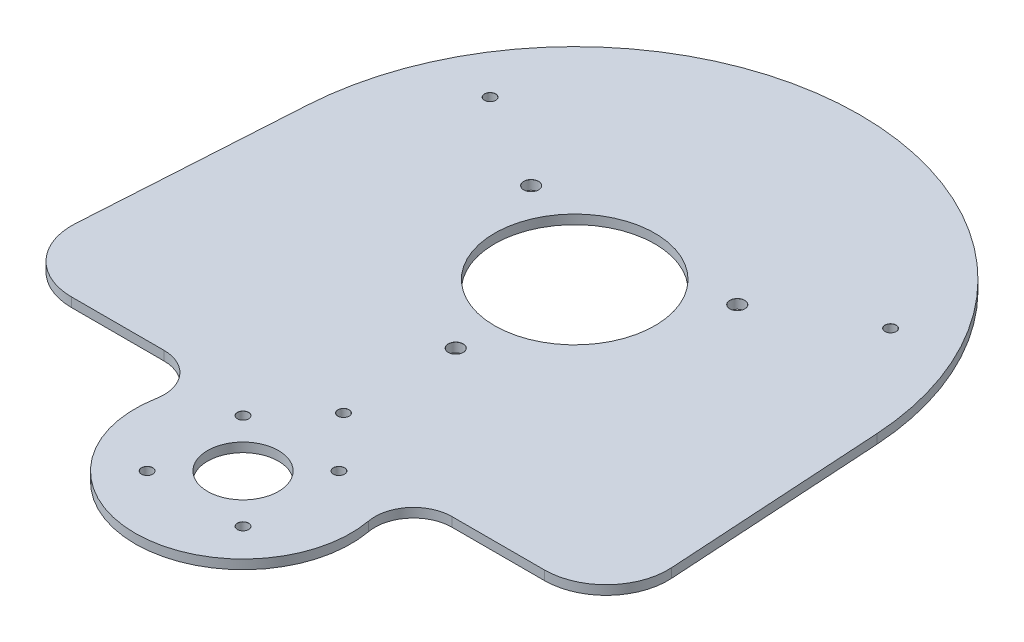
from build123d import *

# Parameters (mm, degrees)
SKETCH1_W                      = 400
SKETCH1_H                      = 400
BOSS_EXTRUDE1_DEPTH            = 3
HOLE1_D                        = 52
HOLE1_DEPTH                    = 10
HOLE2_D                        = 23
HOLE2_DEPTH                    = 100
M4_CLEARANCE_HOLE1_D           = 4.8
M4_CLEARANCE_HOLE1_CSINK_D     = 4.85
M4_CLEARANCE_HOLE1_CSINK_ANGLE = 90
M3_CLEARANCE_HOLE1_D           = 3.6
M3_CLEARANCE_HOLE1_CSINK_D     = 3.65
M3_CLEARANCE_HOLE1_CSINK_ANGLE = 90
SKETCH11_W                     = 667.246369456
SKETCH11_H                     = 555.388303621
CUT_EXTRUDE1_DEPTH             = 1
CUT_EXTRUDE1_DEPTH_BACK        = 4
M3_CLEARANCE_HOLE2_D           = 3.6
M3_CLEARANCE_HOLE2_CSINK_D     = 3.65
M3_CLEARANCE_HOLE2_CSINK_ANGLE = 90


with BuildPart() as part:
    # Sketch1 → Boss-Extrude1 (new body)
    with BuildSketch(Plane(origin=(0, 0, 0), x_dir=(1, 0, 0), z_dir=(0, 1, 0))):
        with Locations((0, -52.110233191)):
            Rectangle(SKETCH1_W, SKETCH1_H)
    extrude(amount=-BOSS_EXTRUDE1_DEPTH)

    # Hole1
    with Locations(Plane(origin=(0, 0, 0), x_dir=(1, 0, 0), z_dir=(0, 1, 0))):
        with Locations((0, 0)):
            Hole(HOLE1_D / 2, depth=HOLE1_DEPTH)

    # Hole2
    with Locations(Plane(origin=(0, 0, 0), x_dir=(1, 0, 0), z_dir=(0, 1, 0))):
        with Locations((0, -107.6)):
            Hole(HOLE2_D / 2, depth=HOLE2_DEPTH)

    # M4 Clearance Hole1 (through all)
    with Locations(Plane(origin=(0, 0, 0), x_dir=(1, 0, 0), z_dir=(0, 1, 0))):
        with Locations((0, -38.6), (33.428580586, 19.3), (-33.428580586, 19.3)):
            CounterSinkHole(M4_CLEARANCE_HOLE1_D / 2, M4_CLEARANCE_HOLE1_CSINK_D / 2, counter_sink_angle=M4_CLEARANCE_HOLE1_CSINK_ANGLE)

    # M3 Clearance Hole1 (through all)
    with Locations(Plane(origin=(0, 0, 0), x_dir=(1, 0, 0), z_dir=(0, 1, 0))):
        with Locations((15.556349186, -92.043650814), (-15.556349186, -92.043650814), (-15.556349186, -123.156349186), (15.556349186, -123.156349186)):
            CounterSinkHole(M3_CLEARANCE_HOLE1_D / 2, M3_CLEARANCE_HOLE1_CSINK_D / 2, counter_sink_angle=M3_CLEARANCE_HOLE1_CSINK_ANGLE)

    # Sketch11 → Cut-Extrude1 (cut, two sides)
    with BuildSketch(Plane(origin=(0, 0, 0), x_dir=(1, 0, 0), z_dir=(0, 1, 0))) as cut_extrude1_sk:
        with Locations((-28.870236031, -19.694924611)):
            Rectangle(SKETCH11_W, SKETCH11_H)
        with BuildLine():
            Line((-46.718297015, -86.518), (-76.718297015, -86.518))
            ThreePointArc((-76.718297015, -86.518), (-91.287101954, -80.220186783), (-96.680745664, -65.292992264))
            Line((-96.680745664, -65.292992264), (-92.326325, 5.665660778))
            ThreePointArc((-92.326325, 5.665660778), (0, 92.5), (92.326325, 5.665660778))
            Line((92.326325, 5.665660778), (96.680745664, -65.292992264))
            ThreePointArc((96.680745664, -65.292992264), (96.708906973, -65.905208425), (96.718297015, -66.518))
            ThreePointArc((96.718297015, -66.518), (90.860432639, -80.660135624), (76.718297015, -86.518))
            Line((76.718297015, -86.518), (46.718297015, -86.518))
            ThreePointArc((46.718297015, -86.518), (37.114124402, -91.017383247), (34.424008327, -101.276421053))
            ThreePointArc((34.424008327, -101.276421053), (34.855704637, -104.425121376), (35, -107.6))
            ThreePointArc((35, -107.6), (-3.174878624, -142.455704637), (-34.424008327, -101.276421053))
            ThreePointArc((-34.424008327, -101.276421053), (-37.114124402, -91.017383247), (-46.718297015, -86.518))
        make_face(mode=Mode.SUBTRACT)
    extrude(amount=CUT_EXTRUDE1_DEPTH, mode=Mode.SUBTRACT)
    extrude(cut_extrude1_sk.sketch, amount=-CUT_EXTRUDE1_DEPTH_BACK, mode=Mode.SUBTRACT)

    # M3 Clearance Hole2 (through all)
    with Locations(Plane(origin=(0, 0, 0), x_dir=(1, 0, 0), z_dir=(0, 1, 0))):
        with Locations((-64.951905284, 37.5), (0, -75), (64.951905284, 37.5)):
            CounterSinkHole(M3_CLEARANCE_HOLE2_D / 2, M3_CLEARANCE_HOLE2_CSINK_D / 2, counter_sink_angle=M3_CLEARANCE_HOLE2_CSINK_ANGLE)


solid = part.part
